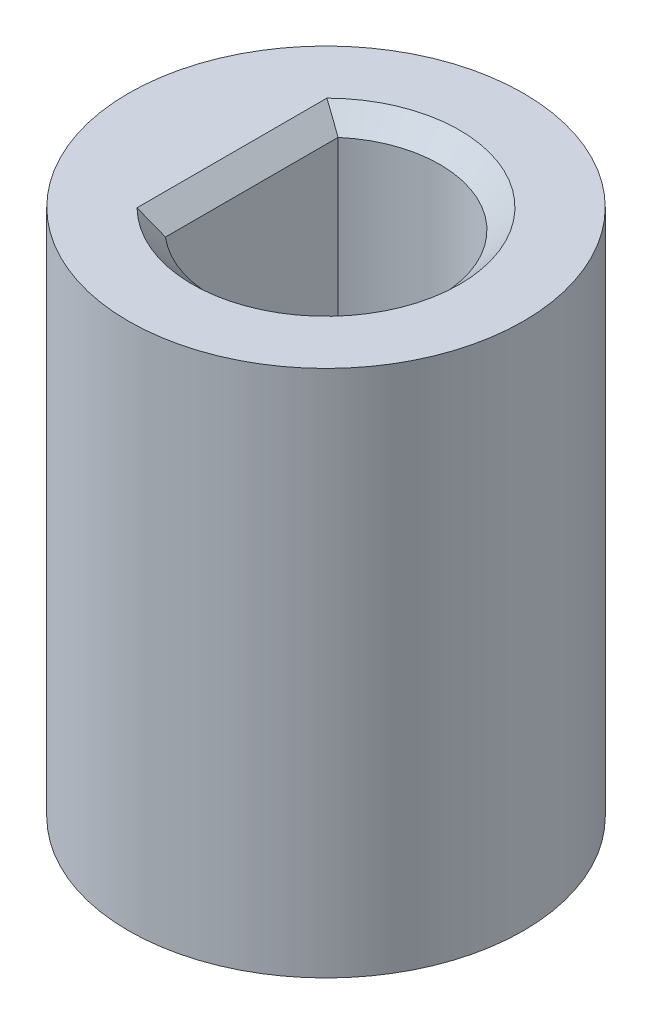
from build123d import *

# Parameters (mm, degrees)
SKETCH1_R           = 2.992461664
BOSS_EXTRUDE1_DEPTH = 8
CHAMFER2_SIZE       = 0.3


with BuildPart() as part:
    # Sketch1 → Boss-Extrude1 (new body)
    with BuildSketch(Plane(origin=(0, 0, 0), x_dir=(1, 0, 0), z_dir=(0, 1, 0))):
        Circle(SKETCH1_R)
        with BuildLine():
            Line((-1.125, 1.307669683), (-1.125, -1.307669683))
            ThreePointArc((-1.125, -1.307669683), (1.725, 0), (-1.125, 1.307669683))
        make_face(mode=Mode.SUBTRACT)
    extrude(amount=BOSS_EXTRUDE1_DEPTH)

    # Chamfer2
    chamfer2_edges = [part.edges().sort_by_distance(p)[0] for p in [
        (1.725, 8, 0),
        (-1.125, 8, 0),
    ]]
    chamfer(chamfer2_edges, length=CHAMFER2_SIZE)


solid = part.part
